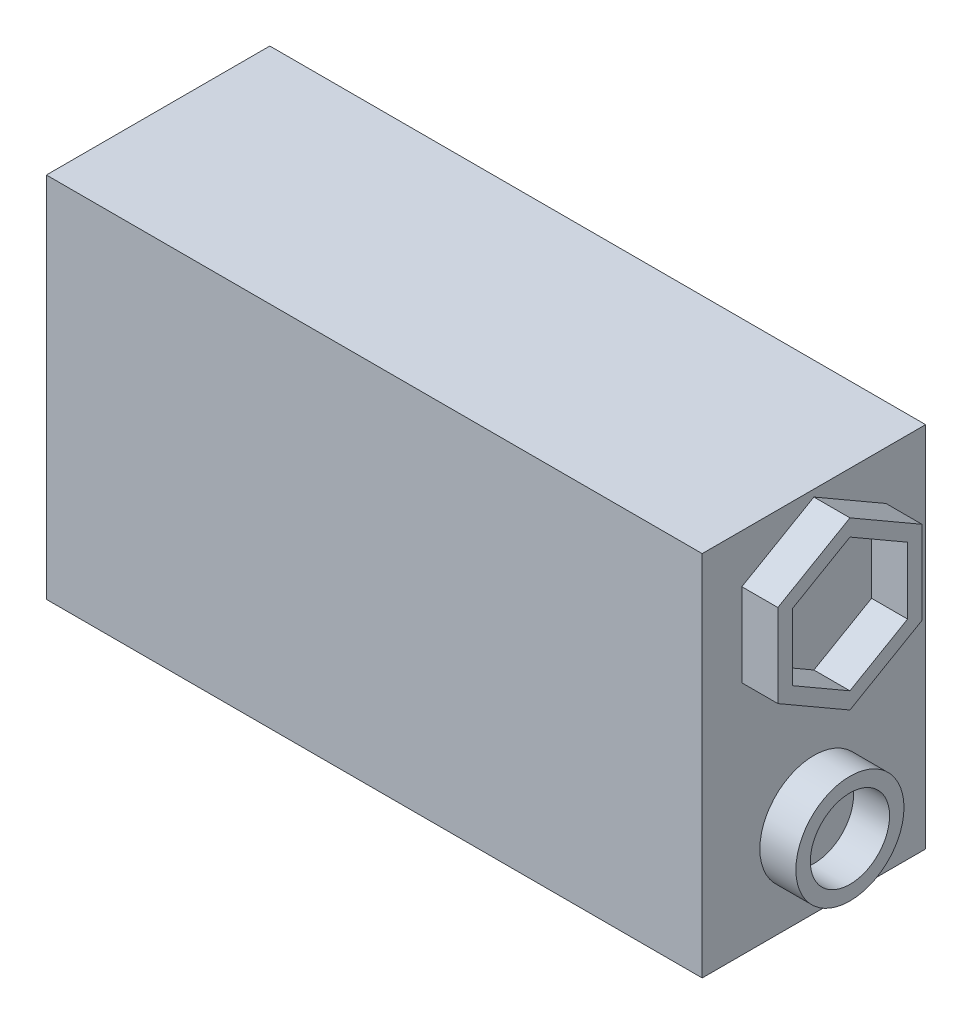
from build123d import *

# Parameters (mm, degrees)
CROQUIS1_W              = 45.5
CROQUIS1_H              = 25.5
SALIENTE_EXTRUIR1_DEPTH = 7.75
CROQUIS2_R              = 3.75
CROQUIS2_R_2            = 2.75
EXTRUIR_L_MINA1_DEPTH   = 2.5


with BuildPart() as part:
    # Croquis1 → Saliente-Extruir1 (new body, symmetric)
    with BuildSketch(Plane.XY):
        Rectangle(CROQUIS1_W, CROQUIS1_H)
    extrude(amount=SALIENTE_EXTRUIR1_DEPTH, both=True)

    # Croquis2 → Extruir-Lámina1 (add)
    with BuildSketch(Plane(origin=(22.75, 0, 0), x_dir=(0, 0, -1), z_dir=(1, 0, 0))):
        with Locations((0, -7)):
            Circle(CROQUIS2_R)
        with Locations((0, -7)):
            Circle(CROQUIS2_R_2, mode=Mode.SUBTRACT)
        Polygon((0, 12.273502692), (-5, 9.386751346), (-5, 3.613248654), (0, 0.726497308), (5, 3.613248654), (5, 9.386751346), align=None)
        Polygon((0, 11.118802154), (-4, 8.809401077), (-4, 4.190598923), (0, 1.881197846), (4, 4.190598923), (4, 8.809401077), align=None, mode=Mode.SUBTRACT)
    extrude(amount=EXTRUIR_L_MINA1_DEPTH)


solid = part.part
